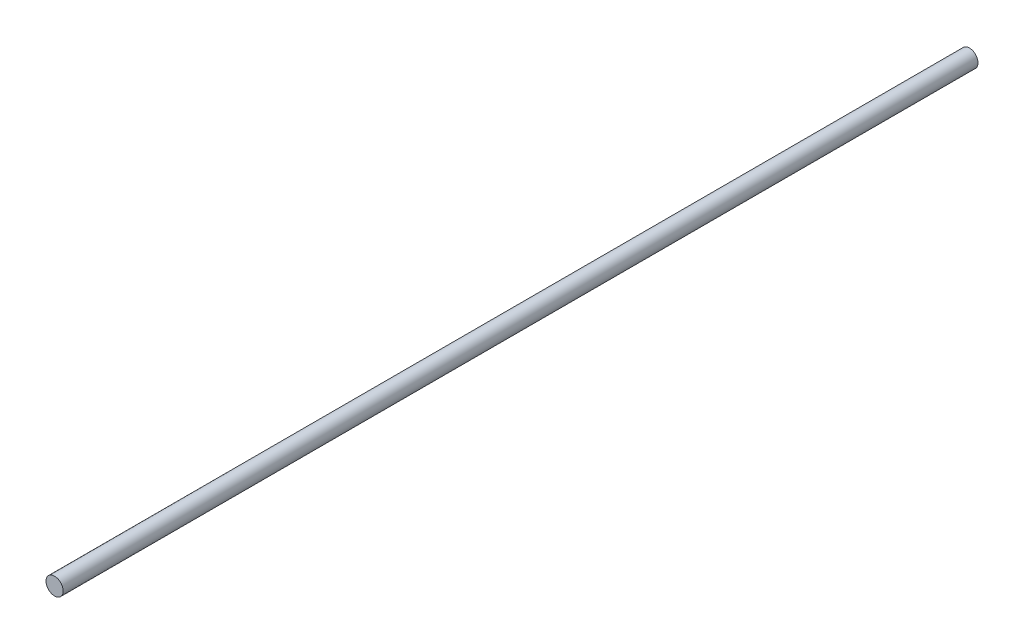
from build123d import *

# Parameters (mm, degrees)
SKETCH1_R           = 4
BOSS_EXTRUDE1_DEPTH = 426


with BuildPart() as part:
    # Sketch1 → Boss-Extrude1 (new body)
    with BuildSketch(Plane.XY):
        Circle(SKETCH1_R)
    extrude(amount=BOSS_EXTRUDE1_DEPTH)


solid = part.part
